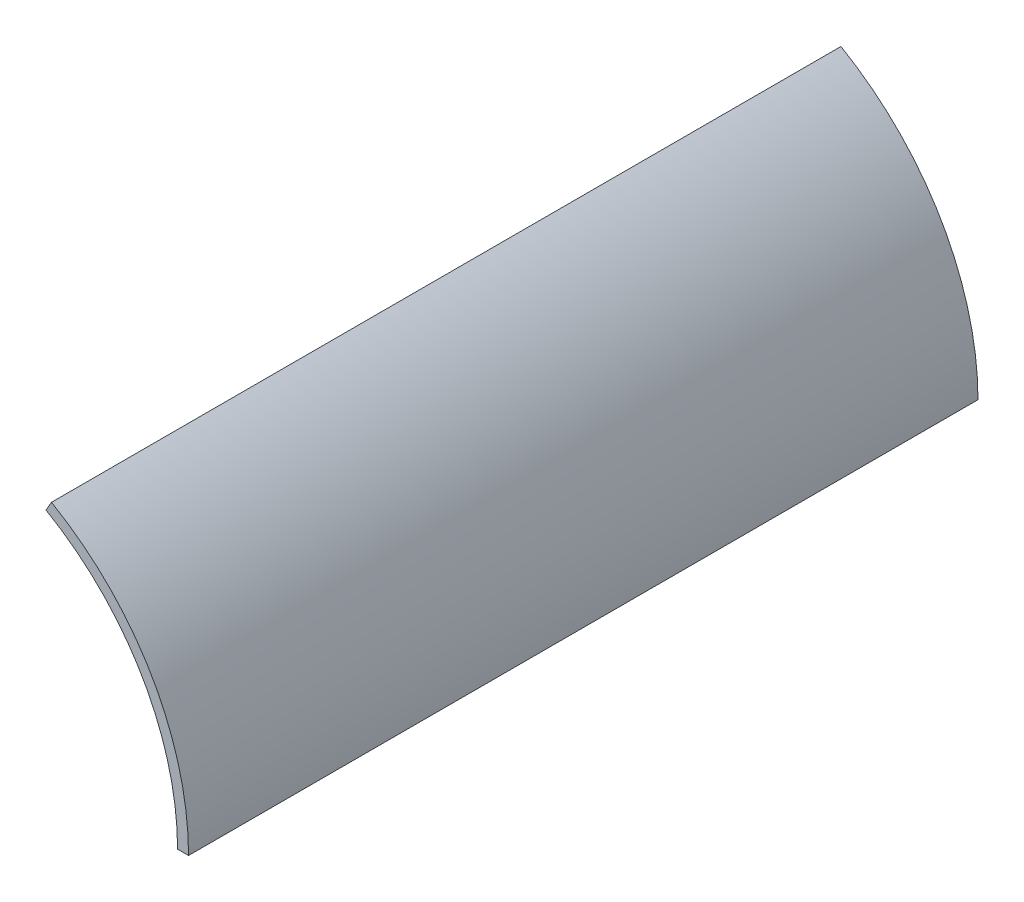
from build123d import *

# Parameters (mm, degrees)
BOSS_EXTRUDE1_DEPTH = 120
BOSS_EXTRUDE2_DEPTH = 60


with BuildPart() as part:
    # Sketch1 → Boss-Extrude1 (new body)
    with BuildSketch(Plane.XY):
        with BuildLine():
            Line((30, 51.961524227), (31.25, 54.126587737))
            ThreePointArc((31.25, 54.126587737), (54.126587737, 31.25), (62.5, 0))
            Line((62.5, 0), (60, 0))
            ThreePointArc((60, 0), (51.961524227, 30), (30, 51.961524227))
        make_face()
    extrude(amount=BOSS_EXTRUDE1_DEPTH)

    # Sketch2 → Boss-Extrude2 (add)
    with BuildSketch(Plane.XY.offset(120)):
        with BuildLine():
            Line((60, 0), (62.5, 0))
            ThreePointArc((62.5, 0), (54.126587737, 31.25), (31.25, 54.126587737))
            Line((31.25, 54.126587737), (30, 51.961524227))
            ThreePointArc((30, 51.961524227), (51.961524227, 30), (60, 0))
        make_face()
    extrude(amount=BOSS_EXTRUDE2_DEPTH)


solid = part.part
